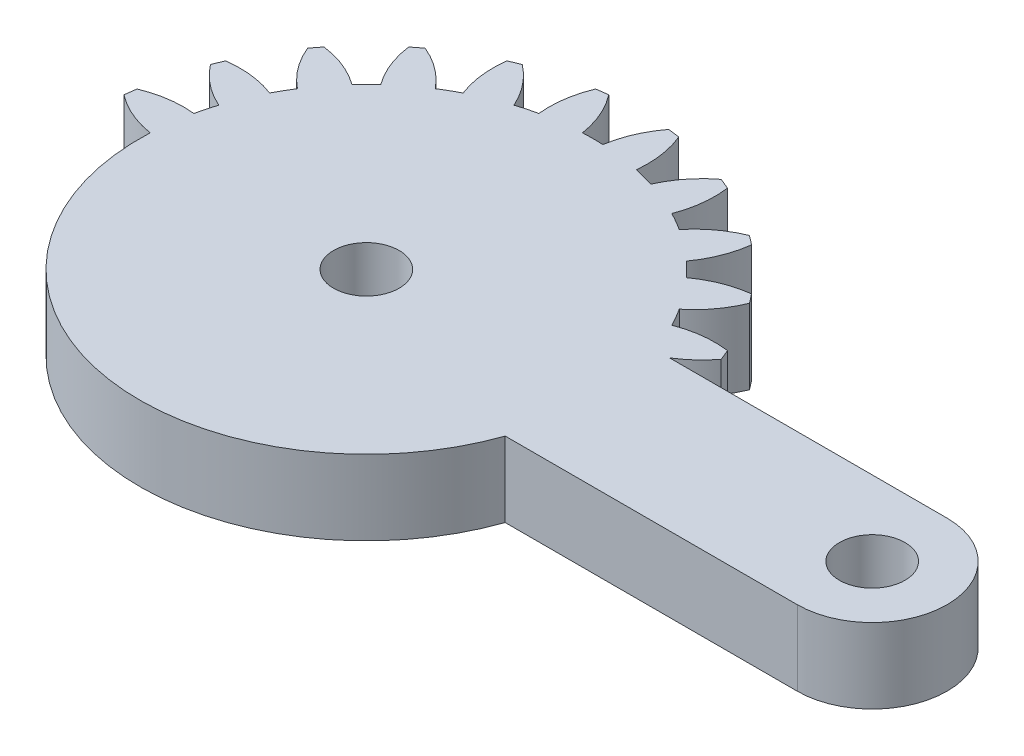
from build123d import *

# Parameters (mm, degrees)
SKETCH1_R           = 1.75
BOSS_EXTRUDE1_DEPTH = 4
CUT_EXTRUDE1_DEPTH  = 10


with BuildPart() as part:
    # Sketch1 → Boss-Extrude1 (new body)
    with BuildSketch(Plane(origin=(0, 0, 0), x_dir=(1, 0, 0), z_dir=(0, 1, 0))):
        with BuildLine():
            Line((16.893657446, 4), (2.081641936, 4))
            ThreePointArc((2.081641936, 4), (2.861028333, 4.588201733), (3.521749436, 5.30713988))
            ThreePointArc((3.521749436, 5.30713988), (3.405395609, 5.596745198), (3.282888305, 5.883801663))
            ThreePointArc((3.282888305, 5.883801663), (1.93527598, 5.894040025), (0.627094961, 5.57027124))
            ThreePointArc((0.627094961, 5.57027124), (0.366286148, 6.046375), (0.084372603, 6.510293938))
            ThreePointArc((0.084372603, 6.510293938), (1.018855105, 7.48132754), (1.683794586, 8.65351323))
            ThreePointArc((1.683794586, 8.65351323), (1.496450048, 8.903135899), (1.303821399, 9.148703928))
            ThreePointArc((1.303821399, 9.148703928), (-0.000522033, 8.809805691), (-1.180330337, 8.158486898))
            ThreePointArc((-1.180330337, 8.158486898), (-1.555477026, 8.550865528), (-1.947855656, 8.926012217))
            ThreePointArc((-1.947855656, 8.926012217), (-1.296536862, 10.105820521), (-0.957638625, 11.410163953))
            ThreePointArc((-0.957638625, 11.410163953), (-1.203206655, 11.602792602), (-1.452829324, 11.79013714))
            ThreePointArc((-1.452829324, 11.79013714), (-2.625015014, 11.125197659), (-3.596048616, 10.190715157))
            ThreePointArc((-3.596048616, 10.190715157), (-4.059967554, 10.472628702), (-4.536071314, 10.733437515))
            ThreePointArc((-4.536071314, 10.733437515), (-4.212302529, 12.041618533), (-4.222540891, 13.389230859))
            ThreePointArc((-4.222540891, 13.389230859), (-4.509597355, 13.511738163), (-4.799202674, 13.62809199))
            ThreePointArc((-4.799202674, 13.62809199), (-5.759348103, 12.682425791), (-6.455432668, 11.528463019))
            ThreePointArc((-6.455432668, 11.528463019), (-6.976508546, 11.680699536), (-7.503891752, 11.809396783))
            ThreePointArc((-7.503891752, 11.809396783), (-7.529737283, 13.156800143), (-7.888414517, 14.455843809))
            ThreePointArc((-7.888414517, 14.455843809), (-8.197396993, 14.499881098), (-8.507248835, 14.537314892))
            ThreePointArc((-8.507248835, 14.537314892), (-9.18992168, 13.375367565), (-9.563620196, 12.080565177))
            ThreePointArc((-9.563620196, 12.080565177), (-10.106342554, 12.09275), (-10.649064912, 12.080565177))
            ThreePointArc((-10.649064912, 12.080565177), (-11.022763428, 13.375367565), (-11.705436272, 14.537314892))
            ThreePointArc((-11.705436272, 14.537314892), (-12.015288115, 14.499881098), (-12.324270591, 14.455843809))
            ThreePointArc((-12.324270591, 14.455843809), (-12.682947825, 13.156800143), (-12.708793355, 11.809396783))
            ThreePointArc((-12.708793355, 11.809396783), (-13.236176561, 11.680699536), (-13.757252439, 11.528463019))
            ThreePointArc((-13.757252439, 11.528463019), (-14.453337005, 12.682425791), (-15.413482434, 13.62809199))
            ThreePointArc((-15.413482434, 13.62809199), (-15.703087752, 13.511738163), (-15.990144217, 13.389230859))
            ThreePointArc((-15.990144217, 13.389230859), (-16.000382579, 12.041618533), (-15.676613793, 10.733437515))
            ThreePointArc((-15.676613793, 10.733437515), (-16.152717554, 10.472628702), (-16.616636492, 10.190715157))
            ThreePointArc((-16.616636492, 10.190715157), (-17.587670094, 11.125197659), (-18.759855783, 11.79013714))
            ThreePointArc((-18.759855783, 11.79013714), (-19.009478453, 11.602792602), (-19.255046482, 11.410163953))
            ThreePointArc((-19.255046482, 11.410163953), (-18.916148245, 10.105820521), (-18.264829452, 8.926012217))
            ThreePointArc((-18.264829452, 8.926012217), (-18.657208082, 8.550865528), (-19.032354771, 8.158486898))
            ThreePointArc((-19.032354771, 8.158486898), (-20.212163074, 8.809805691), (-21.516506507, 9.148703928))
            ThreePointArc((-21.516506507, 9.148703928), (-21.709135156, 8.903135899), (-21.896479694, 8.65351323))
            ThreePointArc((-21.896479694, 8.65351323), (-21.231540213, 7.48132754), (-20.297057711, 6.510293938))
            ThreePointArc((-20.297057711, 6.510293938), (-20.578971255, 6.046375), (-20.839780068, 5.57027124))
            ThreePointArc((-20.839780068, 5.57027124), (-22.147961087, 5.894040025), (-23.495573413, 5.883801663))
            ThreePointArc((-23.495573413, 5.883801663), (-23.618080717, 5.596745198), (-23.734434544, 5.30713988))
            ThreePointArc((-23.734434544, 5.30713988), (-22.788768345, 4.346994451), (-21.634805572, 3.650909885))
            ThreePointArc((-21.634805572, 3.650909885), (-21.78704209, 3.129834008), (-21.915739337, 2.602450802))
            ThreePointArc((-21.915739337, 2.602450802), (-23.263142697, 2.576605271), (-24.562186363, 2.217928037))
            ThreePointArc((-24.562186363, 2.217928037), (-24.606223651, 1.908945561), (-24.643657446, 1.599093719))
            ThreePointArc((-24.643657446, 1.599093719), (-23.481710119, 0.916420874), (-22.186907731, 0.542722358))
            ThreePointArc((-22.186907731, 0.542722358), (-22.199092554, 0), (-22.186907731, -0.542722358))
            ThreePointArc((-22.186907731, -0.542722358), (-23.481710119, -0.916420874), (-24.643657446, -1.599093719))
            ThreePointArc((-24.643657446, -1.599093719), (-24.606223651, -1.908945561), (-24.562186363, -2.217928037))
            ThreePointArc((-24.562186363, -2.217928037), (-23.263142697, -2.576605271), (-21.915739337, -2.602450802))
            ThreePointArc((-21.915739337, -2.602450802), (-21.78704209, -3.129834008), (-21.634805572, -3.650909885))
            ThreePointArc((-21.634805572, -3.650909885), (-22.788768345, -4.346994451), (-23.734434544, -5.30713988))
            ThreePointArc((-23.734434544, -5.30713988), (-23.618080717, -5.596745198), (-23.495573413, -5.883801663))
            ThreePointArc((-23.495573413, -5.883801663), (-22.147961087, -5.894040025), (-20.839780068, -5.57027124))
            ThreePointArc((-20.839780068, -5.57027124), (-20.578971255, -6.046375), (-20.297057711, -6.510293938))
            ThreePointArc((-20.297057711, -6.510293938), (-21.231540213, -7.48132754), (-21.896479694, -8.65351323))
            ThreePointArc((-21.896479694, -8.65351323), (-21.709135156, -8.903135899), (-21.516506507, -9.148703928))
            ThreePointArc((-21.516506507, -9.148703928), (-20.212163074, -8.809805691), (-19.032354771, -8.158486898))
            ThreePointArc((-19.032354771, -8.158486898), (-18.657208082, -8.550865528), (-18.264829452, -8.926012217))
            ThreePointArc((-18.264829452, -8.926012217), (-18.916148245, -10.105820521), (-19.255046482, -11.410163953))
            ThreePointArc((-19.255046482, -11.410163953), (-19.009478453, -11.602792602), (-18.759855783, -11.79013714))
            ThreePointArc((-18.759855783, -11.79013714), (-17.587670094, -11.125197659), (-16.616636492, -10.190715157))
            ThreePointArc((-16.616636492, -10.190715157), (-16.152717554, -10.472628702), (-15.676613793, -10.733437515))
            ThreePointArc((-15.676613793, -10.733437515), (-16.000382579, -12.041618533), (-15.990144217, -13.389230859))
            ThreePointArc((-15.990144217, -13.389230859), (-15.703087752, -13.511738163), (-15.413482434, -13.62809199))
            ThreePointArc((-15.413482434, -13.62809199), (-14.453337005, -12.682425791), (-13.757252439, -11.528463019))
            ThreePointArc((-13.757252439, -11.528463019), (-13.236176561, -11.680699536), (-12.708793355, -11.809396783))
            ThreePointArc((-12.708793355, -11.809396783), (-12.682947825, -13.156800143), (-12.324270591, -14.455843809))
            ThreePointArc((-12.324270591, -14.455843809), (-12.015288115, -14.499881098), (-11.705436272, -14.537314892))
            ThreePointArc((-11.705436272, -14.537314892), (-11.022763428, -13.375367565), (-10.649064912, -12.080565177))
            ThreePointArc((-10.649064912, -12.080565177), (-10.106342554, -12.09275), (-9.563620196, -12.080565177))
            ThreePointArc((-9.563620196, -12.080565177), (-9.18992168, -13.375367565), (-8.507248835, -14.537314892))
            ThreePointArc((-8.507248835, -14.537314892), (-8.197396993, -14.499881098), (-7.888414517, -14.455843809))
            ThreePointArc((-7.888414517, -14.455843809), (-7.529737283, -13.156800143), (-7.503891752, -11.809396783))
            ThreePointArc((-7.503891752, -11.809396783), (-6.976508546, -11.680699536), (-6.455432668, -11.528463019))
            ThreePointArc((-6.455432668, -11.528463019), (-5.759348103, -12.682425791), (-4.799202674, -13.62809199))
            ThreePointArc((-4.799202674, -13.62809199), (-4.509597355, -13.511738163), (-4.222540891, -13.389230859))
            ThreePointArc((-4.222540891, -13.389230859), (-4.212302529, -12.041618533), (-4.536071314, -10.733437515))
            ThreePointArc((-4.536071314, -10.733437515), (-4.059967554, -10.472628702), (-3.596048616, -10.190715157))
            ThreePointArc((-3.596048616, -10.190715157), (-2.625015014, -11.125197659), (-1.452829324, -11.79013714))
            ThreePointArc((-1.452829324, -11.79013714), (-1.203206655, -11.602792602), (-0.957638625, -11.410163953))
            ThreePointArc((-0.957638625, -11.410163953), (-1.296536862, -10.105820521), (-1.947855656, -8.926012217))
            ThreePointArc((-1.947855656, -8.926012217), (-1.555477026, -8.550865528), (-1.180330337, -8.158486898))
            ThreePointArc((-1.180330337, -8.158486898), (-0.000522033, -8.809805691), (1.303821399, -9.148703928))
            ThreePointArc((1.303821399, -9.148703928), (1.496450048, -8.903135899), (1.683794586, -8.65351323))
            ThreePointArc((1.683794586, -8.65351323), (1.018855105, -7.48132754), (0.084372603, -6.510293938))
            ThreePointArc((0.084372603, -6.510293938), (0.366286148, -6.046375), (0.627094961, -5.57027124))
            ThreePointArc((0.627094961, -5.57027124), (1.93527598, -5.894040025), (3.282888305, -5.883801663))
            ThreePointArc((3.282888305, -5.883801663), (3.405395609, -5.596745198), (3.521749436, -5.30713988))
            ThreePointArc((3.521749436, -5.30713988), (2.861028333, -4.588201733), (2.081641936, -4))
            Line((2.081641936, -4), (16.893657446, -4))
            ThreePointArc((16.893657446, -4), (20.893657446, 0), (16.893657446, 4))
        make_face()
        with Locations((-10.106342554, 0)):
            Circle(SKETCH1_R, mode=Mode.SUBTRACT)
        with Locations((16.893657446, 0)):
            Circle(SKETCH1_R, mode=Mode.SUBTRACT)
    extrude(amount=BOSS_EXTRUDE1_DEPTH)

    # Sketch2 → Cut-Extrude1 (cut)
    with BuildSketch(Plane(origin=(0, 4, 0), x_dir=(1, 0, 0), z_dir=(0, 1, 0))):
        with BuildLine():
            ThreePointArc((-24.562186363, -2.217928037), (-23.263142697, -2.576605271), (-21.915739337, -2.602450802))
            ThreePointArc((-21.915739337, -2.602450802), (-22.095637401, -1.578420611), (-22.186907731, -0.542722358))
            ThreePointArc((-22.186907731, -0.542722358), (-23.481710119, -0.916420874), (-24.643657446, -1.599093719))
            ThreePointArc((-24.643657446, -1.599093719), (-24.606223651, -1.908945561), (-24.562186363, -2.217928037))
        make_face()
        with BuildLine():
            ThreePointArc((-23.495573413, -5.883801663), (-22.147961087, -5.894040025), (-20.839780068, -5.57027124))
            ThreePointArc((-20.839780068, -5.57027124), (-21.278586771, -4.627695077), (-21.634805572, -3.650909885))
            ThreePointArc((-21.634805572, -3.650909885), (-22.788768345, -4.346994451), (-23.734434544, -5.30713988))
            ThreePointArc((-23.734434544, -5.30713988), (-23.618080717, -5.596745198), (-23.495573413, -5.883801663))
        make_face()
        with BuildLine():
            ThreePointArc((-21.516506507, -9.148703928), (-20.212163074, -8.809805691), (-19.032354771, -8.158486898))
            ThreePointArc((-19.032354771, -8.158486898), (-19.70016616, -7.361599771), (-20.297057711, -6.510293938))
            ThreePointArc((-20.297057711, -6.510293938), (-21.231540213, -7.48132754), (-21.896479694, -8.65351323))
            ThreePointArc((-21.896479694, -8.65351323), (-21.709135156, -8.903135899), (-21.516506507, -9.148703928))
        make_face()
        with BuildLine():
            ThreePointArc((-18.759855783, -11.79013714), (-17.587670094, -11.125197659), (-16.616636492, -10.190715157))
            ThreePointArc((-16.616636492, -10.190715157), (-17.467942324, -9.593823606), (-18.264829452, -8.926012217))
            ThreePointArc((-18.264829452, -8.926012217), (-18.916148245, -10.105820521), (-19.255046482, -11.410163953))
            ThreePointArc((-19.255046482, -11.410163953), (-19.009478453, -11.602792602), (-18.759855783, -11.79013714))
        make_face()
        with BuildLine():
            ThreePointArc((-15.413482434, -13.62809199), (-14.453337005, -12.682425791), (-13.757252439, -11.528463019))
            ThreePointArc((-13.757252439, -11.528463019), (-14.734037631, -11.172244217), (-15.676613793, -10.733437515))
            ThreePointArc((-15.676613793, -10.733437515), (-16.000382579, -12.041618533), (-15.990144217, -13.389230859))
            ThreePointArc((-15.990144217, -13.389230859), (-15.703087752, -13.511738163), (-15.413482434, -13.62809199))
        make_face()
        with BuildLine():
            ThreePointArc((-11.705436272, -14.537314892), (-11.022763428, -13.375367565), (-10.649064912, -12.080565177))
            ThreePointArc((-10.649064912, -12.080565177), (-11.684763165, -11.989294847), (-12.708793355, -11.809396783))
            ThreePointArc((-12.708793355, -11.809396783), (-12.682947825, -13.156800143), (-12.324270591, -14.455843809))
            ThreePointArc((-12.324270591, -14.455843809), (-12.015288115, -14.499881098), (-11.705436272, -14.537314892))
        make_face()
        with BuildLine():
            ThreePointArc((-7.888414517, -14.455843809), (-7.529737283, -13.156800143), (-7.503891752, -11.809396783))
            ThreePointArc((-7.503891752, -11.809396783), (-8.527921943, -11.989294847), (-9.563620196, -12.080565177))
            ThreePointArc((-9.563620196, -12.080565177), (-9.18992168, -13.375367565), (-8.507248835, -14.537314892))
            ThreePointArc((-8.507248835, -14.537314892), (-8.197396993, -14.499881098), (-7.888414517, -14.455843809))
        make_face()
        with BuildLine():
            ThreePointArc((-4.222540891, -13.389230859), (-4.212302529, -12.041618533), (-4.536071314, -10.733437515))
            ThreePointArc((-4.536071314, -10.733437515), (-5.478647477, -11.172244217), (-6.455432668, -11.528463019))
            ThreePointArc((-6.455432668, -11.528463019), (-5.759348103, -12.682425791), (-4.799202674, -13.62809199))
            ThreePointArc((-4.799202674, -13.62809199), (-4.509597355, -13.511738163), (-4.222540891, -13.389230859))
        make_face()
        with BuildLine():
            ThreePointArc((-0.957638625, -11.410163953), (-1.296536862, -10.105820521), (-1.947855656, -8.926012217))
            ThreePointArc((-1.947855656, -8.926012217), (-2.744742783, -9.593823606), (-3.596048616, -10.190715157))
            ThreePointArc((-3.596048616, -10.190715157), (-2.625015014, -11.125197659), (-1.452829324, -11.79013714))
            ThreePointArc((-1.452829324, -11.79013714), (-1.203206655, -11.602792602), (-0.957638625, -11.410163953))
        make_face()
        with BuildLine():
            ThreePointArc((1.683794586, -8.65351323), (1.018855105, -7.48132754), (0.084372603, -6.510293938))
            ThreePointArc((0.084372603, -6.510293938), (-0.512518948, -7.361599771), (-1.180330337, -8.158486898))
            ThreePointArc((-1.180330337, -8.158486898), (-0.000522033, -8.809805691), (1.303821399, -9.148703928))
            ThreePointArc((1.303821399, -9.148703928), (1.496450048, -8.903135899), (1.683794586, -8.65351323))
        make_face()
        with BuildLine():
            ThreePointArc((3.521749436, -5.30713988), (2.861028333, -4.588201733), (2.081641936, -4))
            Line((2.081641936, -4), (1.305695063, -4))
            ThreePointArc((1.305695063, -4), (0.994195953, -4.797149927), (0.627094961, -5.57027124))
            ThreePointArc((0.627094961, -5.57027124), (1.93527598, -5.894040025), (3.282888305, -5.883801663))
            ThreePointArc((3.282888305, -5.883801663), (3.405395609, -5.596745198), (3.521749436, -5.30713988))
        make_face()
    extrude(amount=-CUT_EXTRUDE1_DEPTH, mode=Mode.SUBTRACT)


solid = part.part
